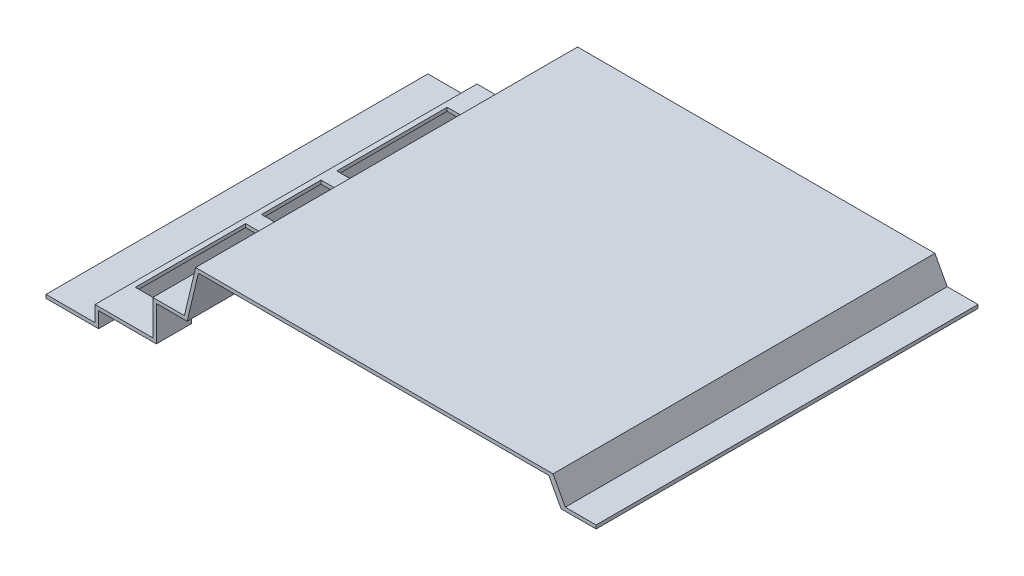
from build123d import *

# Parameters (mm, degrees)
DODANIE_WYCI_GNI_CIE1_DEPTH = 109
SZKIC2_W                    = 30
SZKIC2_H                    = 63
SZKIC2_H_2                  = 34
WYTNIJ_WYCI_GNI_CIE1_DEPTH  = 2
OTW_R_POD_RUB_M41_D         = 4.5
OTW_R_POD_RUB_M41_DEPTH     = 2
SZKIC5_W                    = 28
SZKIC5_H                    = 20
WYTNIJ_WYCI_GNI_CIE2_DEPTH  = 3


with BuildPart() as part:
    # Szkic1 → Dodanie-wyciągnięcie1 (new body, symmetric)
    with BuildSketch(Plane.XY):
        Polygon((0, 0), (0, 2), (28, 2), (28, 11), (61, 11), (61, 31), (79, 31), (85.419782204, 58), (289.419782204, 58), (296.419782204, 45), (314, 45), (314, 43), (294, 43), (287, 56), (87, 56), (80.580217796, 29), (63, 29), (63, 9), (30, 9), (30, 0), align=None)
    extrude(amount=DODANIE_WYCI_GNI_CIE1_DEPTH, both=True)

    # Szkic2 → Wytnij-wyciągnięcie1 (cut)
    with BuildSketch(Plane(origin=(0, 11, 0), x_dir=(1, 0, 0), z_dir=(0, 1, 0))):
        with Locations((46, 57.5)):
            Rectangle(SZKIC2_W, SZKIC2_H)
        with Locations((46, 0)):
            Rectangle(SZKIC2_W, SZKIC2_H_2)
        with Locations((46, -57.5)):
            Rectangle(SZKIC2_W, SZKIC2_H)
    extrude(amount=-WYTNIJ_WYCI_GNI_CIE1_DEPTH, mode=Mode.SUBTRACT)

    # Otwór pod śrubę M41
    with Locations(Plane(origin=(70, 31, 0), x_dir=(0, 0, 1), z_dir=(0, 1, 0))):
        with Locations((0, 0)):
            Hole(OTW_R_POD_RUB_M41_D / 2, depth=OTW_R_POD_RUB_M41_DEPTH)

    # Szkic5 → Wytnij-wyciągnięcie2 (cut)
    with BuildSketch(Plane.ZY.offset(-61)):
        with Locations((-75, 19)):
            Rectangle(SZKIC5_W, SZKIC5_H)
        with Locations((75, 19)):
            Rectangle(SZKIC5_W, SZKIC5_H)
    extrude(amount=-WYTNIJ_WYCI_GNI_CIE2_DEPTH, mode=Mode.SUBTRACT)


solid = part.part
